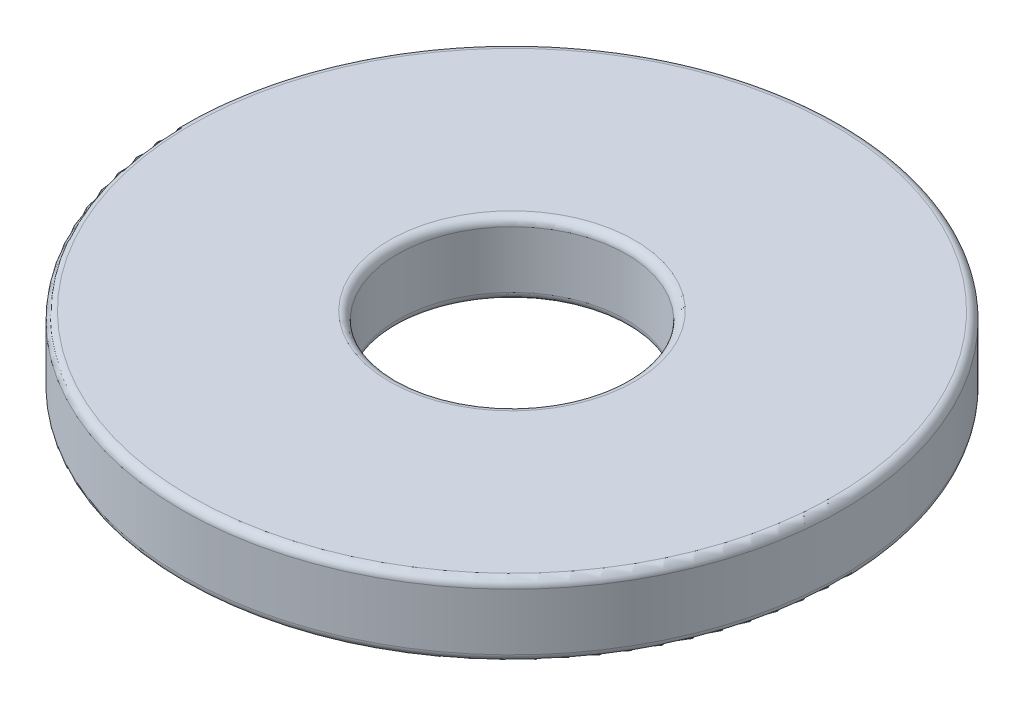
from build123d import *

# Parameters (mm, degrees)
SKETCH1_R           = 5.1562
SKETCH1_R_2         = 1.7907
BOSS_EXTRUDE1_DEPTH = 1.143
FILLET1_R           = 0.127
FILLET2_R           = 0.127
FILLET3_R           = 0.127


with BuildPart() as part:
    # Sketch1 → Boss-Extrude1 (new body)
    with BuildSketch(Plane(origin=(0, 0, 0), x_dir=(1, 0, 0), z_dir=(0, 1, 0))):
        Circle(SKETCH1_R)
        Circle(SKETCH1_R_2, mode=Mode.SUBTRACT)
    extrude(amount=BOSS_EXTRUDE1_DEPTH)

    # Fillet1
    fillet1_edges = [part.edges().sort_by_distance(p)[0] for p in [
        (-5.1562, 1.143, 0),
    ]]
    fillet(fillet1_edges, radius=FILLET1_R)

    # Fillet2
    fillet2_edges = [part.edges().sort_by_distance(p)[0] for p in [
        (-5.1562, 0, 0),
    ]]
    fillet(fillet2_edges, radius=FILLET2_R)

    # Fillet3
    fillet3_edges = [part.edges().sort_by_distance(p)[0] for p in [
        (-1.7907, 0, 0),
        (-1.7907, 1.143, 0),
    ]]
    fillet(fillet3_edges, radius=FILLET3_R)


solid = part.part
